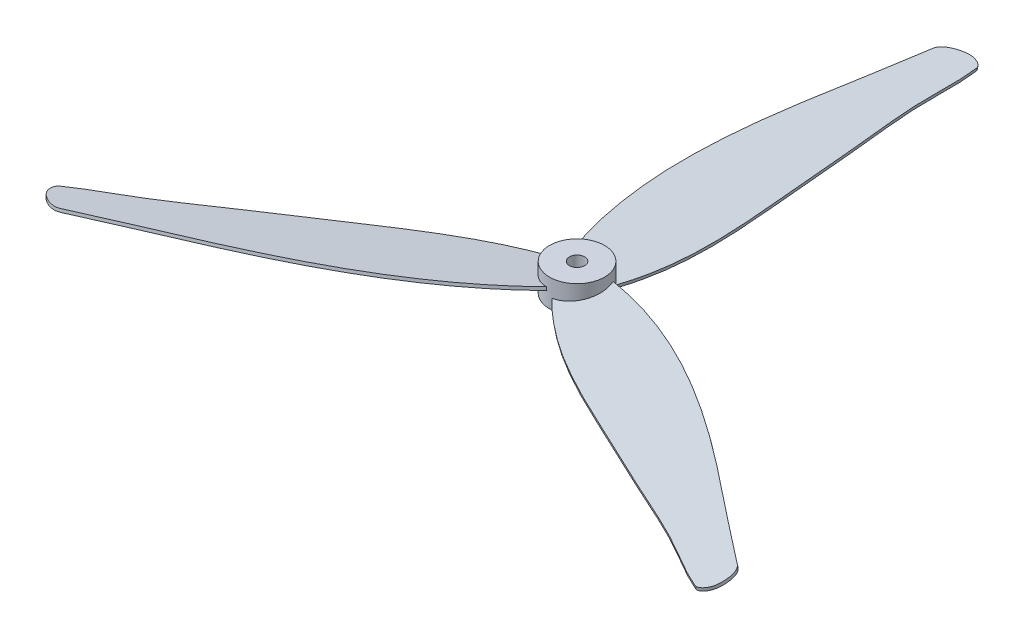
from build123d import *

# Parameters (mm, degrees)
SKETCH1_R           = 9
SKETCH1_R_2         = 2.5
BOSS_EXTRUDE1_DEPTH = 9
BOSS_EXTRUDE2_START = -4.5
BOSS_EXTRUDE2_DEPTH = 1
CIRPATTERN1_COUNT   = 3


with BuildPart() as part:
    # Sketch1 → Boss-Extrude1 (new body)
    with BuildSketch(Plane(origin=(0, 0, 0), x_dir=(1, 0, 0), z_dir=(0, 1, 0))):
        Circle(SKETCH1_R)
        Circle(SKETCH1_R_2, mode=Mode.SUBTRACT)
    extrude(amount=BOSS_EXTRUDE1_DEPTH)

    # Sketch2 → Boss-Extrude2 (add)
    with BuildSketch(Plane(origin=(0, 0, 0), x_dir=(0.503077915, -0.078217233, 0.860694299), z_dir=(0.078217233, -0.987688341, -0.135476221)).offset(BOSS_EXTRUDE2_START)):
        with BuildLine():
            ThreePointArc((7.057167207, 3.522296079), (6.485622082, -4.488528141), (-0.810263482, -7.845613536))
            add(Edge.make_bspline(
                [(-0.810263482, -7.845613536), (14.84556885, -26.528236143), (50.110026658, -46.96867352), (87.58233528, -60.277903004), (104.394373747, -67.496596406), (108.694675079, -65.622418883), (111.839467858, -62.293667025), (111.674369285, -59.14487647), (110.334821186, -58.189477886), (105.387973441, -54.647266008), (93.470266374, -48.531390342), (77.381003607, -36.65329381), (48.752102578, -17.489898423), (26.964124286, -1.279240997), (7.057167207, 3.522296079)],
                knots=[0, 0, 0, 0, 0.282933447, 0.46648255, 0.471857062, 0.495005992, 0.514382548, 0.523354602, 0.526650828, 0.533187201, 0.595375398, 0.682473253, 0.767935763, 1, 1, 1, 1], degree=3))
        make_face()
    boss_extrude2 = extrude(amount=BOSS_EXTRUDE2_DEPTH)

    # CirPattern1: Boss-Extrude2 ×3 about axis
    cirpattern1_axis = Axis((0, 9, 0), (0, 1, 0))
    for i in range(1, CIRPATTERN1_COUNT):
        add(boss_extrude2.rotate(cirpattern1_axis, i * 360 / CIRPATTERN1_COUNT))


solid = part.part
